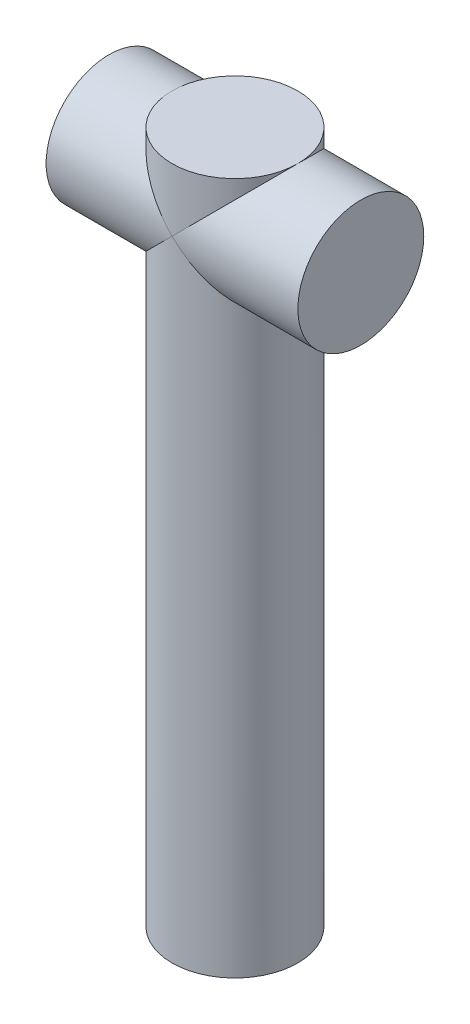
from build123d import *

# Parameters (mm, degrees)
ESBO_O1_R                     = 15
RESSALTO_EXTRUS_O1_DEPTH      = 165
RESSALTO_EXTRUS_O2_DEPTH      = 30
RESSALTO_EXTRUS_O2_DEPTH_BACK = 30
ESBO_O3_R                     = 15


with BuildPart() as part:
    # Esboço1 → Ressalto-extrusão1 (new body)
    with BuildSketch(Plane(origin=(0, 0, 0), x_dir=(1, 0, 0), z_dir=(0, 1, 0))):
        Circle(ESBO_O1_R)
    extrude(amount=-RESSALTO_EXTRUS_O1_DEPTH)

    # Esboço3 → Ressalto-extrusão2 (add, two sides: drawn at the far end of the back side and taken through both)
    with BuildSketch(Plane(origin=(0, 0, 0), x_dir=(0, 0, -1), z_dir=(1, 0, 0)).offset(-RESSALTO_EXTRUS_O2_DEPTH_BACK)):
        with Locations((0, -15)):
            Circle(ESBO_O3_R)
    extrude(amount=RESSALTO_EXTRUS_O2_DEPTH + RESSALTO_EXTRUS_O2_DEPTH_BACK)


solid = part.part
